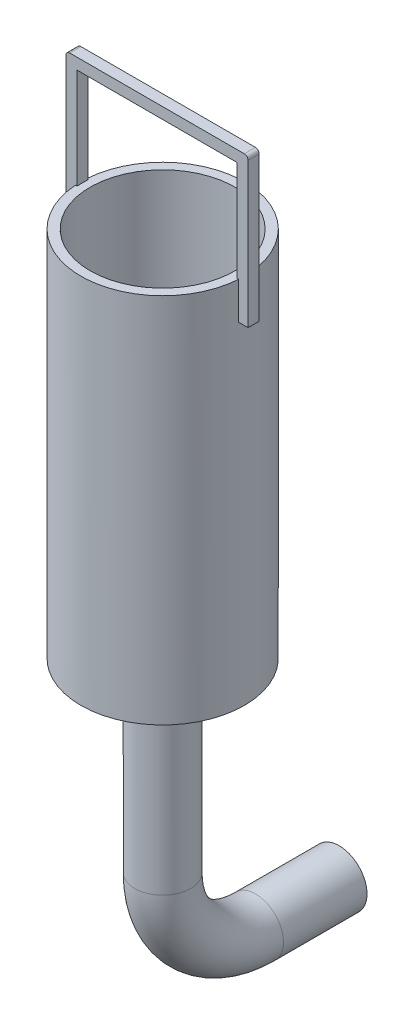
from build123d import *

# Parameters (mm, degrees)
ESBO_O1_R                     = 44
RESSALTO_EXTRUS_O1_DEPTH      = 200
ESBO_O2_R                     = 39
CORTE_EXTRUS_O1_DEPTH         = 192
CORTE_EXTRUS_O2_REACH         = 203.832
ESBO_O3_R                     = 15.7
RESSALTO_EXTRUS_O2_DEPTH      = 3
RESSALTO_EXTRUS_O2_DEPTH_BACK = 3
FILETE1_R                     = 2
SWEEP_THIN1_PROFILE_R         = 15
SWEEP_THIN1_PROFILE_R_2       = 14


with BuildPart() as part:
    # Esboço1 → Ressalto-extrusão1 (new body)
    with BuildSketch(Plane(origin=(0, 0, 0), x_dir=(1, 0, 0), z_dir=(0, 1, 0))):
        Circle(ESBO_O1_R)
    extrude(amount=RESSALTO_EXTRUS_O1_DEPTH)

    # Esboço2 → Corte-extrusão1 (cut)
    with BuildSketch(Plane(origin=(0, 200, 0), x_dir=(1, 0, 0), z_dir=(0, 1, 0))):
        Circle(ESBO_O2_R)
    extrude(amount=-CORTE_EXTRUS_O1_DEPTH, mode=Mode.SUBTRACT)

    # Esboço3 → Corte-extrusão2 (cut, up to next)
    with BuildSketch(Plane(origin=(0, 8, 0), x_dir=(1, 0, 0), z_dir=(0, 1, 0)), mode=Mode.PRIVATE) as corte_extrus_o2_sk1:
        Circle(ESBO_O3_R)
    corte_extrus_o2_tool1 = extrude(corte_extrus_o2_sk1.sketch, amount=-CORTE_EXTRUS_O2_REACH, mode=Mode.PRIVATE) & part.part
    add(corte_extrus_o2_tool1.solids().sort_by_distance((0, 8, 0))[0], mode=Mode.SUBTRACT)

    # Esboço4 → Ressalto-extrusão2 (add, two sides: drawn at the far end of the back side and taken through both)
    with BuildSketch(Plane.XY.offset(-RESSALTO_EXTRUS_O2_DEPTH_BACK)):
        Polygon((-49.040737885, 260), (-49.040737885, 180), (-43.040737885, 180), (-43.040737885, 254), (42.942783163, 254), (42.942783163, 180), (48.942783163, 180), (48.942783163, 260), align=None)
    extrude(amount=RESSALTO_EXTRUS_O2_DEPTH + RESSALTO_EXTRUS_O2_DEPTH_BACK)

    # Filete1
    filete1_edges = [part.edges().sort_by_distance(p)[0] for p in [
        (-49.040737885, 260, 0),
        (48.942783163, 260, 0),
    ]]
    fillet(filete1_edges, radius=FILETE1_R)


with BuildPart() as body_2:
    # Sweep-Thin1: sweep along a curve in space
    with BuildLine() as sweep_thin1_path:
        Line((0, 0, 0), (0, -99.810784889, 0))
        ThreePointArc((0, -149.810784889, -50), (0, -135.166123949, -14.644660941), (0, -99.810784889, 0))
        Line((0, -149.810784889, -50), (0, -149.810784889, -94.950630416))
    # Sweep-Thin1 profile (on start of the path) → Sweep-Thin1 (sweep)
    with BuildSketch(Plane(origin=(0, 0, 0), x_dir=(0, 0, -1), z_dir=(0, -1, 0))):
        Circle(SWEEP_THIN1_PROFILE_R)
        Circle(SWEEP_THIN1_PROFILE_R_2, mode=Mode.SUBTRACT)
    sweep(path=sweep_thin1_path.line)


solid = Compound([part.part, body_2.part])
